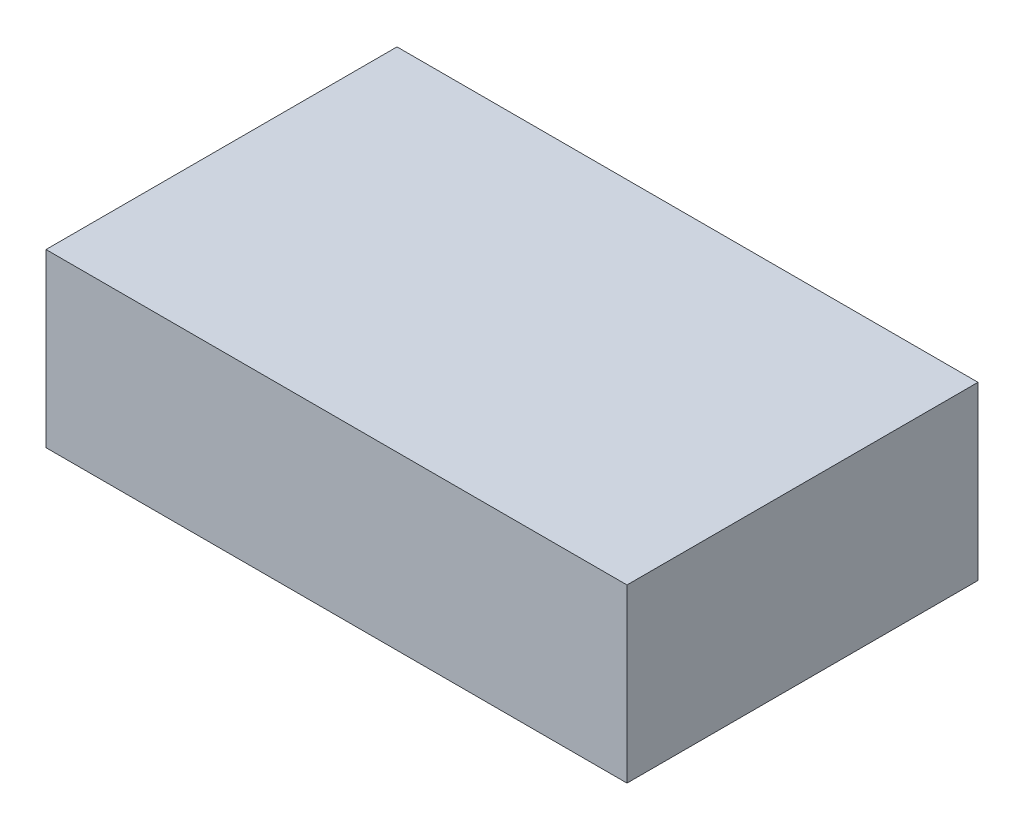
from build123d import *

# Parameters (mm, degrees)
SKETCH1_W           = 18
SKETCH1_H           = 13
SKETCH1_R           = 0.5
SKETCH1_R_2         = 1.5
BOSS_EXTRUDE1_DEPTH = 1.5
SKETCH2_W           = 18
SKETCH2_H           = 13
SKETCH2_W_2         = 5.077229708
SKETCH2_H_2         = 3.067324783
CUT_EXTRUDE1_DEPTH  = 2.5


with BuildPart() as part:
    # Sketch1 → Boss-Extrude1 (new body)
    with BuildSketch(Plane(origin=(0, 0, 0), x_dir=(1, 0, 0), z_dir=(0, 1, 0))):
        with Locations((9, -6.5)):
            Rectangle(SKETCH1_W, SKETCH1_H)
        with Locations((1.38, -1.38)):
            Circle(SKETCH1_R, mode=Mode.SUBTRACT)
        with Locations((3.92, -1.38)):
            Circle(SKETCH1_R, mode=Mode.SUBTRACT)
        with Locations((6.46, -1.38)):
            Circle(SKETCH1_R, mode=Mode.SUBTRACT)
        with Locations((9, -1.38)):
            Circle(SKETCH1_R, mode=Mode.SUBTRACT)
        with Locations((11.54, -1.38)):
            Circle(SKETCH1_R, mode=Mode.SUBTRACT)
        with Locations((14.08, -1.38)):
            Circle(SKETCH1_R, mode=Mode.SUBTRACT)
        with Locations((16.62, -1.38)):
            Circle(SKETCH1_R, mode=Mode.SUBTRACT)
        with Locations((2.63, -10.37)):
            Circle(SKETCH1_R_2, mode=Mode.SUBTRACT)
    extrude(amount=-BOSS_EXTRUDE1_DEPTH)

    # Sketch2 → Cut-Extrude1 (cut, through all)
    with BuildSketch(Plane(origin=(0, 0, 0), x_dir=(1, 0, 0), z_dir=(0, 1, 0))):
        with Locations((9, -6.5)):
            Rectangle(SKETCH2_W, SKETCH2_H)
        with Locations((9.369954861, -10.033021679)):
            Rectangle(SKETCH2_W_2, SKETCH2_H_2, mode=Mode.SUBTRACT)
    extrude(amount=-CUT_EXTRUDE1_DEPTH, mode=Mode.SUBTRACT)


solid = part.part
